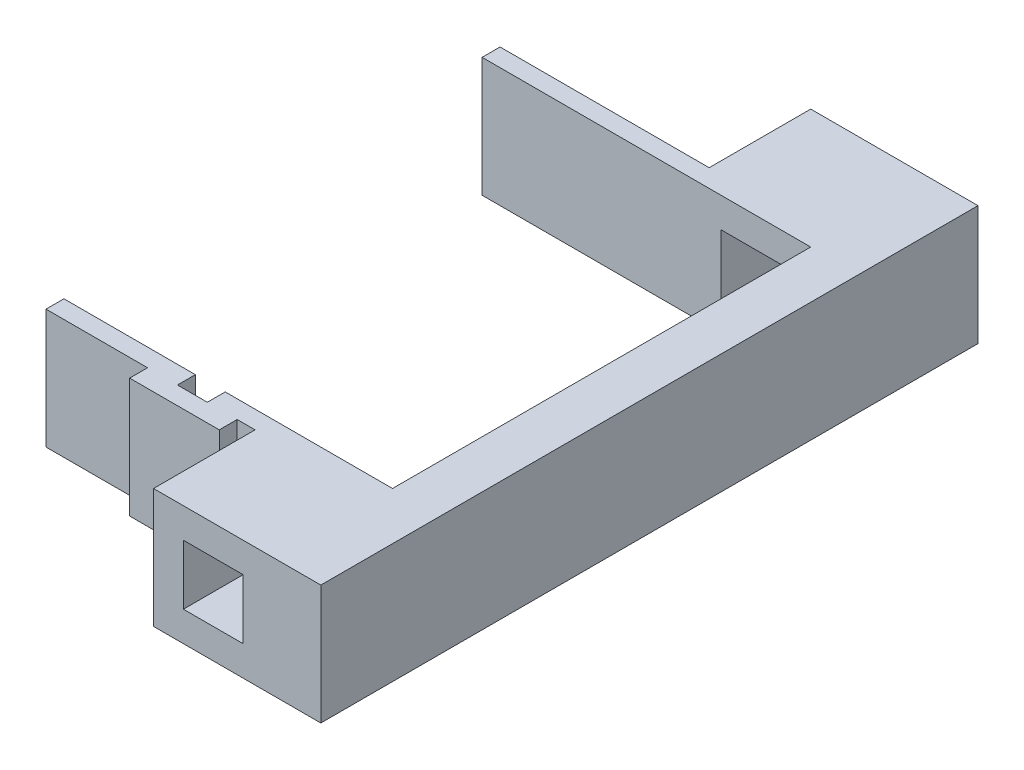
from build123d import *

# Parameters (mm, degrees)
SKETCH1_W           = 20
SKETCH1_H           = 20
BOSS_EXTRUDE1_DEPTH = 10
SKETCH3_W           = 10
SKETCH3_H           = 10
CUT_EXTRUDE1_DEPTH  = 111
SKETCH4_W           = 35
SKETCH4_H           = 3
BOSS_EXTRUDE2_DEPTH = 10


with BuildPart() as part:
    # Sketch1 → Boss-Extrude1 (new body, symmetric)
    with BuildSketch(Plane(origin=(0, 0, 0), x_dir=(1, 0, 0), z_dir=(0, 1, 0))):
        Polygon((10, 35), (10, -35), (10, -55), (18, -55), (18, 55), (10, 55), align=None)
        with Locations((0, -45)):
            Rectangle(SKETCH1_W, SKETCH1_H)
        with Locations((0, 45)):
            Rectangle(SKETCH1_W, SKETCH1_H)
    extrude(amount=BOSS_EXTRUDE1_DEPTH, both=True)

    # Sketch3 → Cut-Extrude1 (cut, through all)
    with BuildSketch(Plane.XY.offset(55)):
        Rectangle(SKETCH3_W, SKETCH3_H)
    extrude(amount=-CUT_EXTRUDE1_DEPTH, mode=Mode.SUBTRACT)

    # Sketch4 → Boss-Extrude2 (add, symmetric)
    with BuildSketch(Plane(origin=(0, 0, 0), x_dir=(1, 0, 0), z_dir=(0, 1, 0))):
        Polygon((-10, -38), (-10, -35), (-18, -35), (-18, -38), (-23, -38), (-23, -35), (-45, -35), (-45, -38), (-28, -38), (-28, -41), (-13, -41), (-13, -38), align=None)
        with Locations((-27.5, 36.5)):
            Rectangle(SKETCH4_W, SKETCH4_H)
    extrude(amount=BOSS_EXTRUDE2_DEPTH, both=True)


solid = part.part
